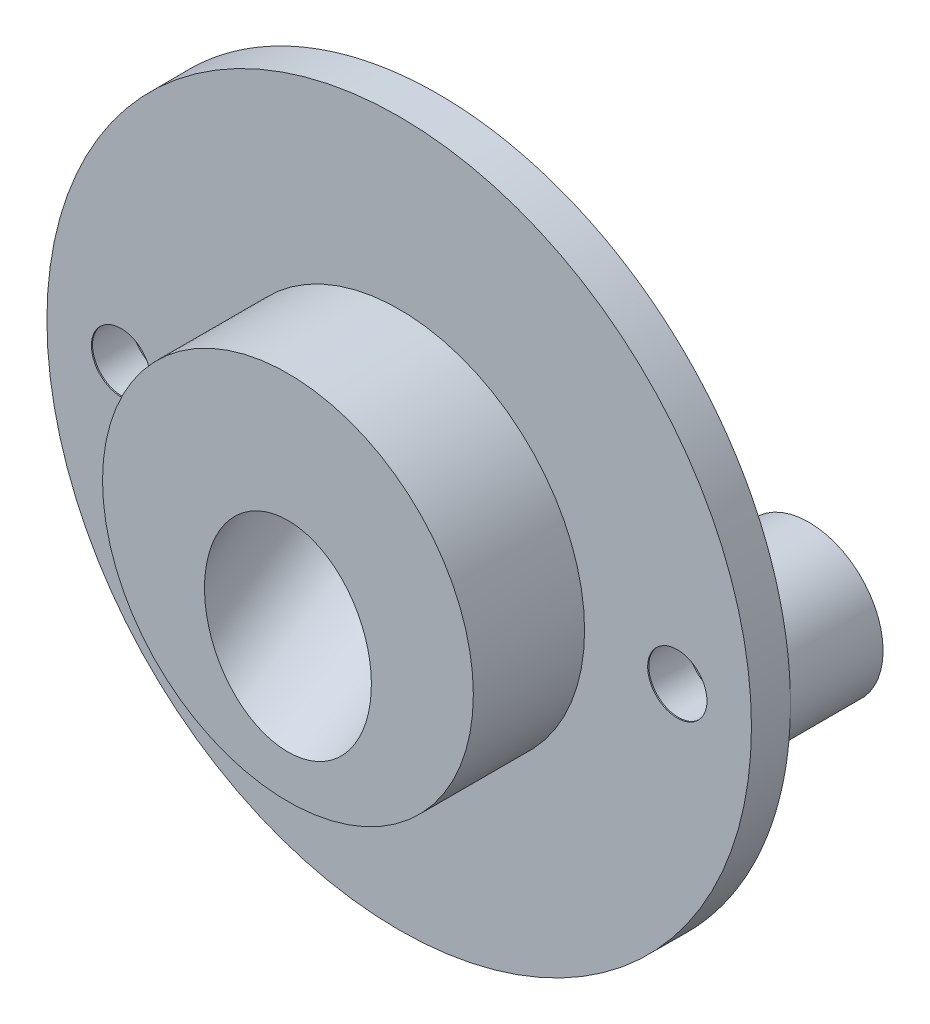
from build123d import *

# Parameters (mm, degrees)
ESQUISSE1_R                                        = 19
BOSS_EXTRU_1_DEPTH                                 = 2.1
ESQUISSE2_R                                        = 10
BOSS_EXTRU_2_DEPTH                                 = 6
ESQUISSE4_R                                        = 4.5
ENL_V_MAT_EXTRU_1_DEPTH                            = 21
ESQUISSE5_R                                        = 6
ENL_V_MAT_EXTRU_2_DEPTH                            = 7.2
ENL_V_MAT_EXTRU_3_DEPTH                            = 4.2
ENL_V_MAT_EXTRU_3_DEPTH_BACK                       = 10
CONG_1_R                                           = 4
ESQUISSE7_R                                        = 1.6
ENL_V_MAT_EXTRU_4_DEPTH                            = 4.2
CONG_2_R                                           = 4
ESQUISSE8_W                                        = 24.922206
ESQUISSE8_H                                        = 11.327448
ENL_V_MAT_EXTRU_5_DEPTH                            = 25
ESQUISSE9_R                                        = 4
ESQUISSE9_R_2                                      = 1.6
BOSS_EXTRU_4_DEPTH                                 = 5
CHAMBRAGE_POUR_VIS_T_TE_RONDE_BOMB_E_M_D           = 3.5
CHAMBRAGE_POUR_VIS_T_TE_RONDE_BOMB_E_M_DEPTH       = 6.948494
CHAMBRAGE_POUR_VIS_T_TE_RONDE_BOMB_E_M_CBORE_D     = 4.35
CHAMBRAGE_POUR_VIS_T_TE_RONDE_BOMB_E_M_CBORE_DEPTH = 4.8
CHAMBRAGE_POUR_VIS_T_TE_RONDE_BOMB_E_M_TIP         = 1.051506


with BuildPart() as part:
    # Esquisse1 → Boss.-Extru.1 (new body)
    with BuildSketch(Plane.XY):
        Circle(ESQUISSE1_R)
    extrude(amount=BOSS_EXTRU_1_DEPTH)

    # Esquisse2 → Boss.-Extru.2 (add)
    with BuildSketch(Plane.XY.offset(2.1)):
        Circle(ESQUISSE2_R)
    extrude(amount=BOSS_EXTRU_2_DEPTH)

    # Esquisse3 → Révolution1 (revolve)
    with BuildSketch(Plane(origin=(0, 0, 0), x_dir=(0, 0, -1), z_dir=(1, 0, 0))):
        Polygon((7.5, 0), (0, -11.25), (0, 0), align=None)
    revolve(axis=Axis((0, 0, 0), (0, 0, -1)))

    # Esquisse4 → Enlèv. mat.-Extru.1 (cut)
    with BuildSketch(Plane(origin=(0, 3.461538, -5.192308), x_dir=(0, 0.83205, 0.5547), z_dir=(0, 0.5547, -0.83205))):
        with Locations((2.600157, 0)):
            Circle(ESQUISSE4_R)
    extrude(amount=-ENL_V_MAT_EXTRU_1_DEPTH, mode=Mode.SUBTRACT)

    # Esquisse5 → Enlèv. mat.-Extru.2 (cut)
    with BuildSketch(Plane(origin=(0, 3.461538, -5.192308), x_dir=(0, 0.83205, 0.5547), z_dir=(0, 0.5547, -0.83205))):
        with Locations((2.600157, 0)):
            Circle(ESQUISSE5_R)
    extrude(amount=-ENL_V_MAT_EXTRU_2_DEPTH, mode=Mode.SUBTRACT)

    # Esquisse6 → Enlèv. mat.-Extru.3 (cut, two sides)
    with BuildSketch(Plane(origin=(0, 0, 0), x_dir=(1, 0, 0), z_dir=(0, 1, 0))) as enl_v_mat_extru_3_sk:
        with BuildLine():
            Line((2.748075, 5.66795), (0, 7.5))
            Line((0, 7.5), (-2.748075, 5.66795))
            ThreePointArc((-2.748075, 5.66795), (0, 6.5), (2.748075, 5.66795))
        make_face()
    extrude(amount=ENL_V_MAT_EXTRU_3_DEPTH, mode=Mode.SUBTRACT)
    extrude(enl_v_mat_extru_3_sk.sketch, amount=-ENL_V_MAT_EXTRU_3_DEPTH_BACK, mode=Mode.SUBTRACT)

    # Congé1
    cong_1_edges = [part.edges().sort_by_distance(p)[0] for p in [
        (-1.569953, -1.039687, -6.244664),
    ]]
    fillet(cong_1_edges, radius=CONG_1_R)

    # Esquisse7 → Enlèv. mat.-Extru.4 (cut)
    with BuildSketch(Plane(origin=(0, 0, 0), x_dir=(-1, 0, 0), z_dir=(0, 0, -1))):
        with Locations((-15, 0)):
            Circle(ESQUISSE7_R)
        with Locations((15, 0)):
            Circle(ESQUISSE7_R)
    extrude(amount=-ENL_V_MAT_EXTRU_4_DEPTH, mode=Mode.SUBTRACT)

    # Congé2
    cong_2_edges = [part.edges().sort_by_distance(p)[0] for p in [
        (0, 11.25, 0),
    ]]
    fillet(cong_2_edges, radius=CONG_2_R)

    # Esquisse8 → Enlèv. mat.-Extru.5 (cut, symmetric)
    with BuildSketch(Plane(origin=(0, 0, 0), x_dir=(1, 0, 0), z_dir=(0, 1, 0))):
        with Locations((0, 5.663724)):
            Rectangle(ESQUISSE8_W, ESQUISSE8_H)
    extrude(amount=ENL_V_MAT_EXTRU_5_DEPTH, both=True, mode=Mode.SUBTRACT)

    # Esquisse9 → Boss.-Extru.4 (add)
    with BuildSketch(Plane(origin=(0, 0, 0), x_dir=(-1, 0, 0), z_dir=(0, 0, -1))):
        with Locations((-15, 0)):
            Circle(ESQUISSE9_R)
        with Locations((-15, 0)):
            Circle(ESQUISSE9_R_2, mode=Mode.SUBTRACT)
        with Locations((15, 0)):
            Circle(ESQUISSE9_R)
        with Locations((15, 0)):
            Circle(ESQUISSE9_R_2, mode=Mode.SUBTRACT)
    extrude(amount=BOSS_EXTRU_4_DEPTH)

    # Chambrage pour vis à tête ronde bombée M21
    with Locations(Plane(origin=(15, 0, -5), x_dir=(-1, 0, 0), z_dir=(0, 0, -1))):
        with Locations((0, 0), (30, 0)):
            CounterBoreHole(CHAMBRAGE_POUR_VIS_T_TE_RONDE_BOMB_E_M_D / 2, CHAMBRAGE_POUR_VIS_T_TE_RONDE_BOMB_E_M_CBORE_D / 2, CHAMBRAGE_POUR_VIS_T_TE_RONDE_BOMB_E_M_CBORE_DEPTH, depth=CHAMBRAGE_POUR_VIS_T_TE_RONDE_BOMB_E_M_DEPTH)
            with Locations((0, 0, -(CHAMBRAGE_POUR_VIS_T_TE_RONDE_BOMB_E_M_DEPTH + CHAMBRAGE_POUR_VIS_T_TE_RONDE_BOMB_E_M_TIP / 2))):  # 118° drill point
                Cone(0, CHAMBRAGE_POUR_VIS_T_TE_RONDE_BOMB_E_M_D / 2, CHAMBRAGE_POUR_VIS_T_TE_RONDE_BOMB_E_M_TIP, mode=Mode.SUBTRACT)


solid = part.part
